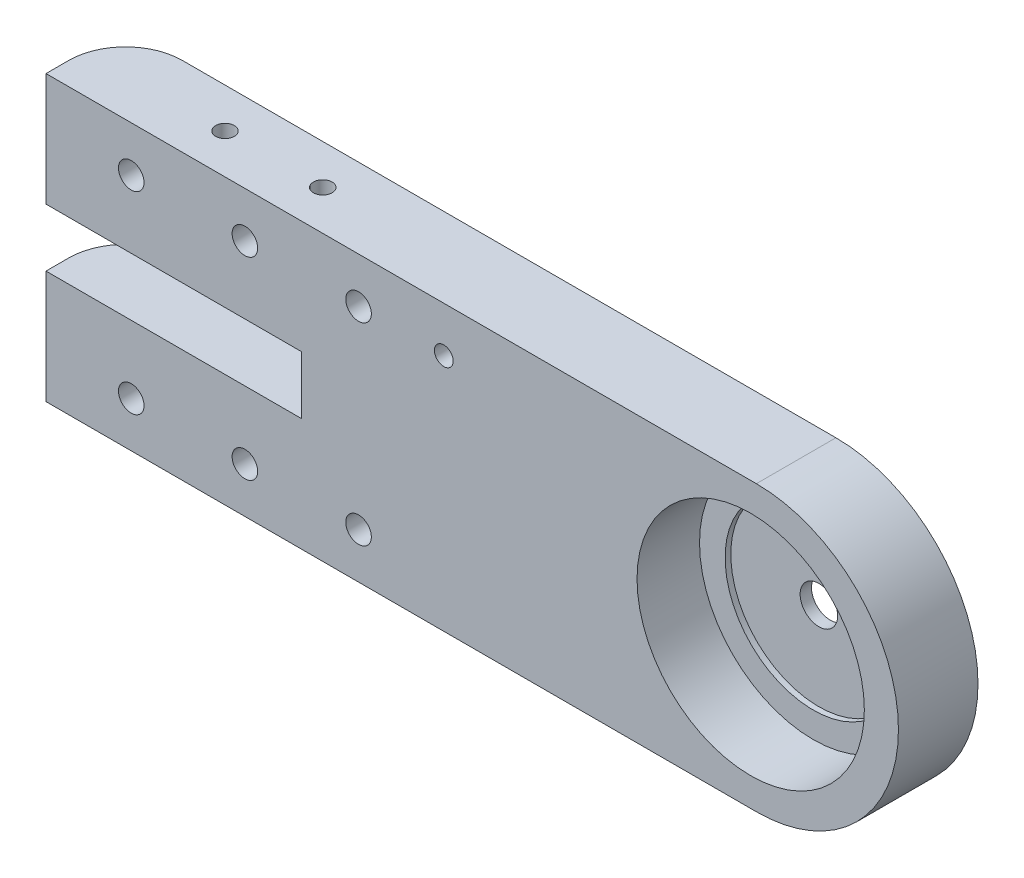
from build123d import *

# Parameters (mm, degrees)
BOSS_EXTRUDE1_DEPTH       = 14
SKETCH2_W                 = 45
SKETCH2_H                 = 10.2
CUT_EXTRUDE1_DEPTH        = 15
F_4_CLEARANCE_HOLE1_D     = 3.3
F_4_CLEARANCE_HOLE1_DEPTH = 14
F_4_CLEARANCE_HOLE2_D     = 3.3
F_4_CLEARANCE_HOLE2_DEPTH = 19.899999999
F_8_CLEARANCE_HOLE1_D     = 4.5
F_8_CLEARANCE_HOLE1_DEPTH = 14
CHAMFER1_SIZE             = 2.45
FILLET1_R                 = 10


with BuildPart() as part:
    # Sketch1 → Boss-Extrude1 (new body)
    with BuildSketch(Plane.XY.offset(14)):
        with BuildLine():
            Line((125, 0), (0, 0))
            Line((0, 0), (0, -50))
            Line((0, -50), (125, -50))
            ThreePointArc((125, -50), (150, -25), (125, 0))
        make_face()
    extrude(amount=-BOSS_EXTRUDE1_DEPTH)

    # Sketch2 → Cut-Extrude1 (cut, through all)
    with BuildSketch(Plane(origin=(0, 0, 0), x_dir=(-1, 0, 0), z_dir=(0, 0, -1))):
        with Locations((-22.5, -24.999999999)):
            Rectangle(SKETCH2_W, SKETCH2_H)
    extrude(amount=-CUT_EXTRUDE1_DEPTH, mode=Mode.SUBTRACT)

    # Sketch3 → Cut-Revolve1 (revolve, cut)
    with BuildSketch(Plane(origin=(0, -24.999999999, 0), x_dir=(1, 0, 0), z_dir=(0, 1, 0))):
        Polygon((127.3, 0), (123.999999995, 0), (123.999999995, -14), (144, -14), (144, -3), (139.5, -3), (139.5, -2), (127.3, -2), align=None)
    revolve(axis=Axis((123.999999995, -24.999999999, 0), (0, 0, 1)), mode=Mode.SUBTRACT)

    # #4 Clearance Hole1
    with Locations(Plane(origin=(0, 0, 0), x_dir=(-1, 0, 0), z_dir=(0, 0, -1))):
        with Locations((-70, -8)):
            Hole(F_4_CLEARANCE_HOLE1_D / 2, depth=F_4_CLEARANCE_HOLE1_DEPTH)

    # #4 Clearance Hole2
    with Locations(Plane(origin=(0, 0, 0), x_dir=(1, 0, 0), z_dir=(0, 1, 0))):
        with Locations((24.5, -7), (41.7, -7)):
            Hole(F_4_CLEARANCE_HOLE2_D / 2, depth=F_4_CLEARANCE_HOLE2_DEPTH)

    # #8 Clearance Hole1
    with Locations(Plane(origin=(0, 0, 0), x_dir=(-1, 0, 0), z_dir=(0, 0, -1))):
        with Locations((-15, -8), (-15, -42), (-35, -42), (-35, -8), (-55, -8), (-55, -42)):
            Hole(F_8_CLEARANCE_HOLE1_D / 2, depth=F_8_CLEARANCE_HOLE1_DEPTH)

    # Chamfer1
    chamfer1_edges = [part.edges().sort_by_distance(p)[0] for p in [
        (52.75, -42, 0),
        (52.75, -8, 0),
        (32.75, -8, 0),
        (32.75, -42, 0),
        (12.75, -42, 0),
        (12.75, -8, 0),
    ]]
    chamfer(chamfer1_edges, length=CHAMFER1_SIZE)

    # Fillet1
    fillet1_edges = [part.edges().sort_by_distance(p)[0] for p in [
        (0, -9.95, 0),
        (0, -40.05, 0),
    ]]
    fillet(fillet1_edges, radius=FILLET1_R)


solid = part.part
